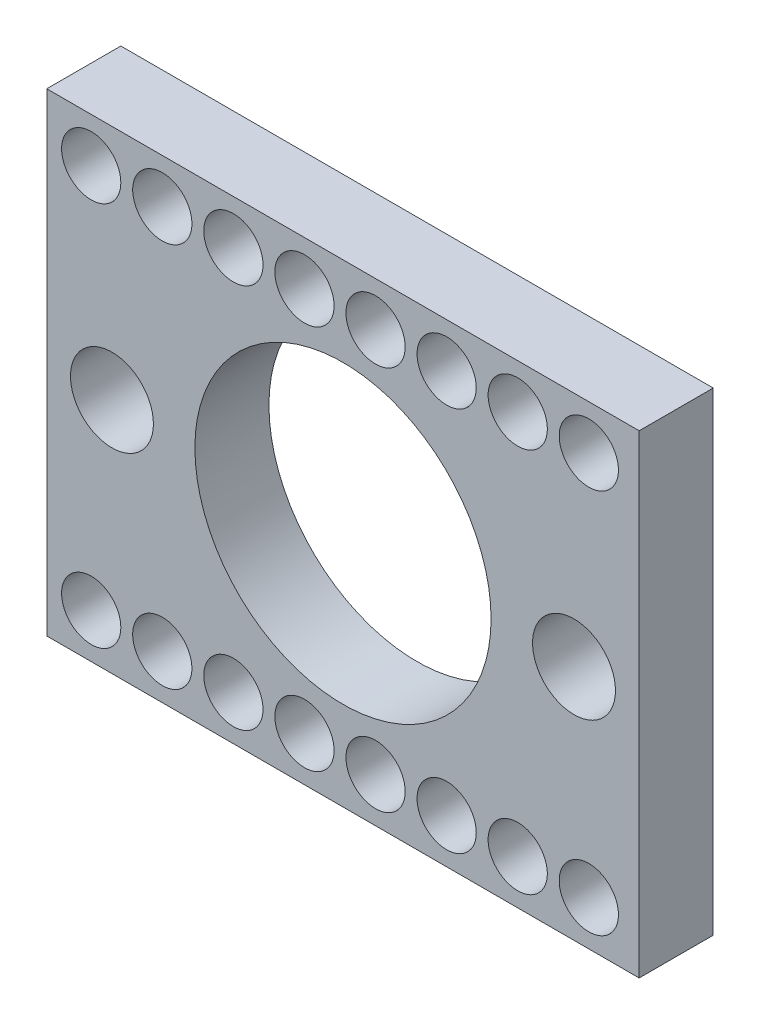
from build123d import *

# Parameters (mm, degrees)
SKETCH2_W           = 25.4
SKETCH2_H           = 20.32
SKETCH2_R           = 6.35
SKETCH2_R_2         = 1.778
BOSS_EXTRUDE1_DEPTH = 3.175
SKETCH4_R           = 1.27
CUT_EXTRUDE1_DEPTH  = 3.175


with BuildPart() as part:
    # Sketch2 → Boss-Extrude1 (new body)
    with BuildSketch(Plane.XY):
        with Locations((-1.045882353, 0)):
            Rectangle(SKETCH2_W, SKETCH2_H)
        with Locations((-1.045882353, 0)):
            Circle(SKETCH2_R, mode=Mode.SUBTRACT)
        with Locations((-10.951882353, 0)):
            Circle(SKETCH2_R_2, mode=Mode.SUBTRACT)
        with Locations((8.860117647, 0)):
            Circle(SKETCH2_R_2, mode=Mode.SUBTRACT)
    extrude(amount=BOSS_EXTRUDE1_DEPTH)

    # Sketch4 → Cut-Extrude1 (cut)
    with BuildSketch(Plane.XY.offset(3.175)):
        with Locations((-11.840882353, 8.255)):
            Circle(SKETCH4_R)
        with Locations((-8.792882353, 8.255)):
            Circle(SKETCH4_R)
        with Locations((-5.744882353, 8.255)):
            Circle(SKETCH4_R)
        with Locations((-2.696882353, 8.255)):
            Circle(SKETCH4_R)
        with Locations((0.351117647, 8.255)):
            Circle(SKETCH4_R)
        with Locations((3.399117647, 8.255)):
            Circle(SKETCH4_R)
        with Locations((6.447117647, 8.255)):
            Circle(SKETCH4_R)
        with Locations((9.495117647, 8.255)):
            Circle(SKETCH4_R)
        with Locations((-11.840882353, -8.255)):
            Circle(SKETCH4_R)
        with Locations((-8.792882353, -8.255)):
            Circle(SKETCH4_R)
        with Locations((-5.744882353, -8.255)):
            Circle(SKETCH4_R)
        with Locations((-2.696882353, -8.255)):
            Circle(SKETCH4_R)
        with Locations((0.351117647, -8.255)):
            Circle(SKETCH4_R)
        with Locations((3.399117647, -8.255)):
            Circle(SKETCH4_R)
        with Locations((6.447117647, -8.255)):
            Circle(SKETCH4_R)
        with Locations((9.495117647, -8.255)):
            Circle(SKETCH4_R)
    extrude(amount=-CUT_EXTRUDE1_DEPTH, mode=Mode.SUBTRACT)


solid = part.part
